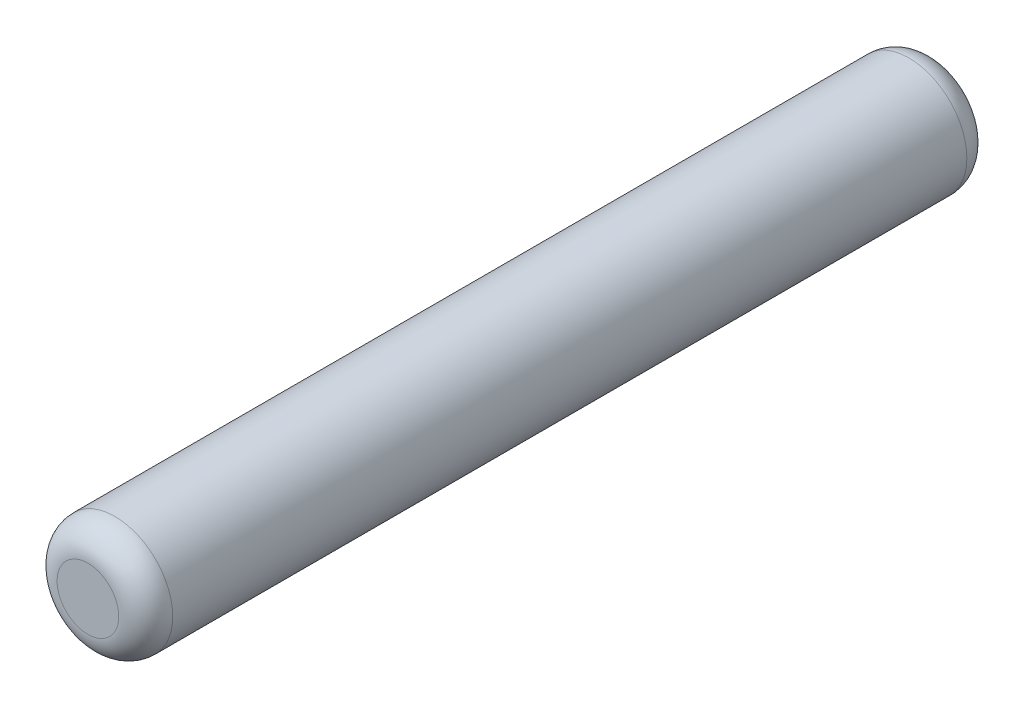
from build123d import *

# Parameters (mm, degrees)
SKETCH1_R           = 0.75
BOSS_EXTRUDE1_DEPTH = 5.5
FILLET1_R           = 0.35


with BuildPart() as part:
    # Sketch1 → Boss-Extrude1 (new body, symmetric)
    with BuildSketch(Plane.XY):
        Circle(SKETCH1_R)
    extrude(amount=BOSS_EXTRUDE1_DEPTH, both=True)

    # Fillet1
    fillet1_edges = [part.edges().sort_by_distance(p)[0] for p in [
        (-0.75, 0, -5.5),
        (-0.75, 0, 5.5),
    ]]
    fillet(fillet1_edges, radius=FILLET1_R)


solid = part.part
